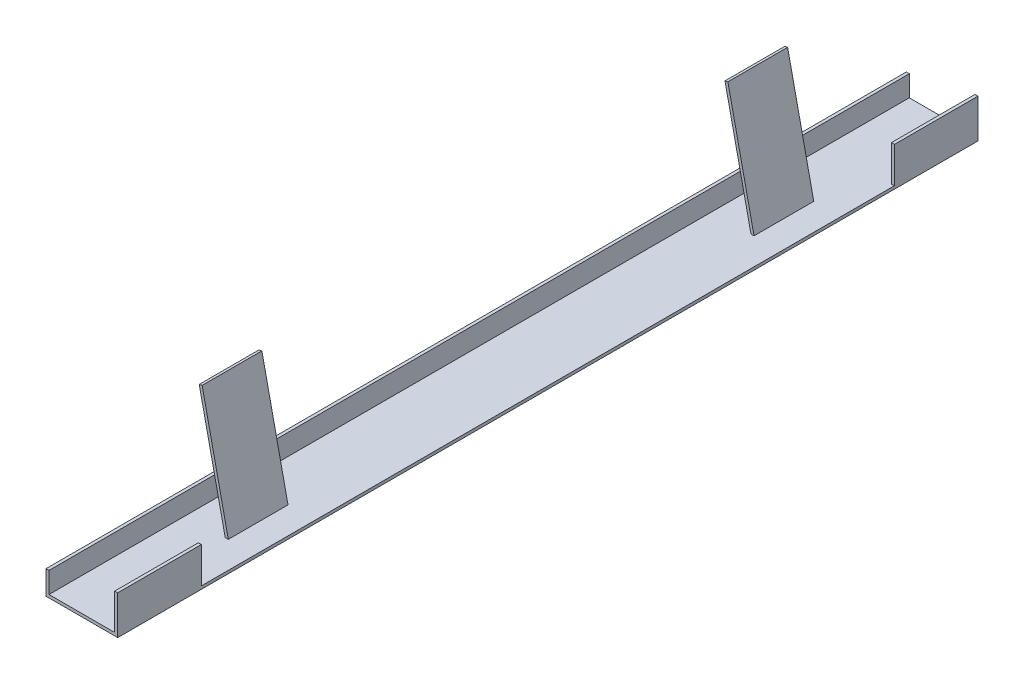
from build123d import *

# Parameters (mm, degrees)
EXTRUDE1_DEPTH     = 228.6
CUT_EXTRUDE1_DEPTH = 123.825
CUT_EXTRUDE2_DEPTH = 73.025
CUT_EXTRUDE3_DEPTH = 73.025
SKETCH6_W          = 1.5875
SKETCH6_H          = 19.05
CUT_EXTRUDE4_DEPTH = 184.15


with BuildPart() as part:
    # Sketch2 → Extrude1 (new body, symmetric)
    with BuildSketch(Plane.XY):
        Polygon((101.6, 12.7), (101.6, 0), (139.7, 0), (139.7, 20.6375), (138.1125, 20.6375), (138.1125, 1.5875), (125.449578796, 1.5875), (111.549753001, 65.526698647), (109.998485525, 65.189466588), (123.825, 1.5875), (103.1875, 1.5875), (103.1875, 12.7), align=None)
    extrude(amount=EXTRUDE1_DEPTH, both=True)

    # Sketch3 → Cut-Extrude1 (cut, symmetric)
    with BuildSketch(Plane.XY):
        Polygon((103.1875, 1.5875), (138.1125, 1.5875), (138.1125, 20.6375), (111.549753001, 65.526698647), (109.998485525, 65.189466588), (103.1875, 12.7), align=None)
    extrude(amount=CUT_EXTRUDE1_DEPTH, both=True, mode=Mode.SUBTRACT)

    # Sketch4 → Cut-Extrude2 (cut)
    with BuildSketch(Plane.XY.offset(228.6)):
        Polygon((103.1875, 12.7), (103.1875, 1.5875), (138.1125, 1.5875), (138.1125, 20.6375), (111.549753001, 65.526698647), (109.998485525, 65.189466588), align=None)
    extrude(amount=-CUT_EXTRUDE2_DEPTH, mode=Mode.SUBTRACT)

    # Sketch5 → Cut-Extrude3 (cut)
    with BuildSketch(Plane(origin=(0, 0, -228.6), x_dir=(-1, 0, 0), z_dir=(0, 0, -1))):
        Polygon((-138.1125, 20.6375), (-138.1125, 1.5875), (-103.1875, 1.5875), (-103.1875, 12.7), (-109.998485525, 65.189466588), (-111.549753001, 65.526698647), align=None)
    extrude(amount=-CUT_EXTRUDE3_DEPTH, mode=Mode.SUBTRACT)

    # Sketch6 → Cut-Extrude4 (cut, symmetric)
    with BuildSketch(Plane.XY):
        with Locations((138.90625, 11.1125)):
            Rectangle(SKETCH6_W, SKETCH6_H)
    extrude(amount=CUT_EXTRUDE4_DEPTH, both=True, mode=Mode.SUBTRACT)


solid = part.part
